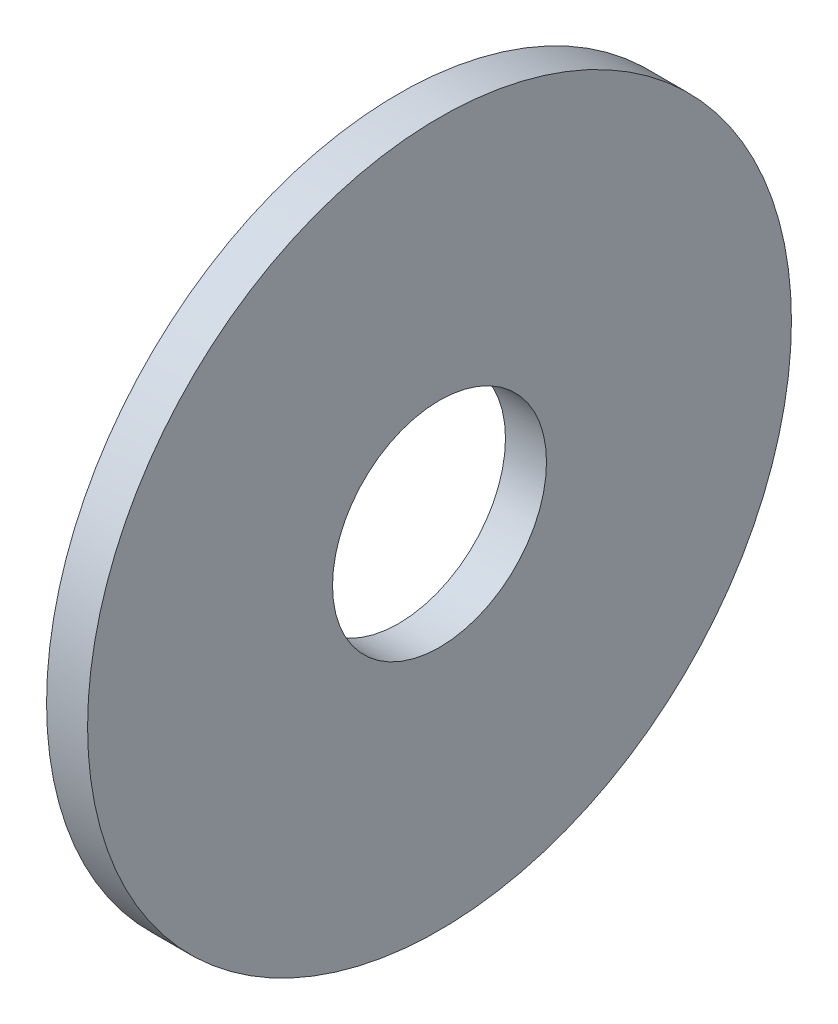
from build123d import *

# Parameters (mm, degrees)
SKETCH1_R           = 11.1125
SKETCH1_R_2         = 3.3782
BOSS_EXTRUDE1_DEPTH = 1.2954


with BuildPart() as part:
    # Sketch1 → Boss-Extrude1 (new body)
    with BuildSketch(Plane(origin=(0, 0, 0), x_dir=(0, 0, -1), z_dir=(1, 0, 0))):
        Circle(SKETCH1_R)
        Circle(SKETCH1_R_2, mode=Mode.SUBTRACT)
    extrude(amount=BOSS_EXTRUDE1_DEPTH)


solid = part.part
